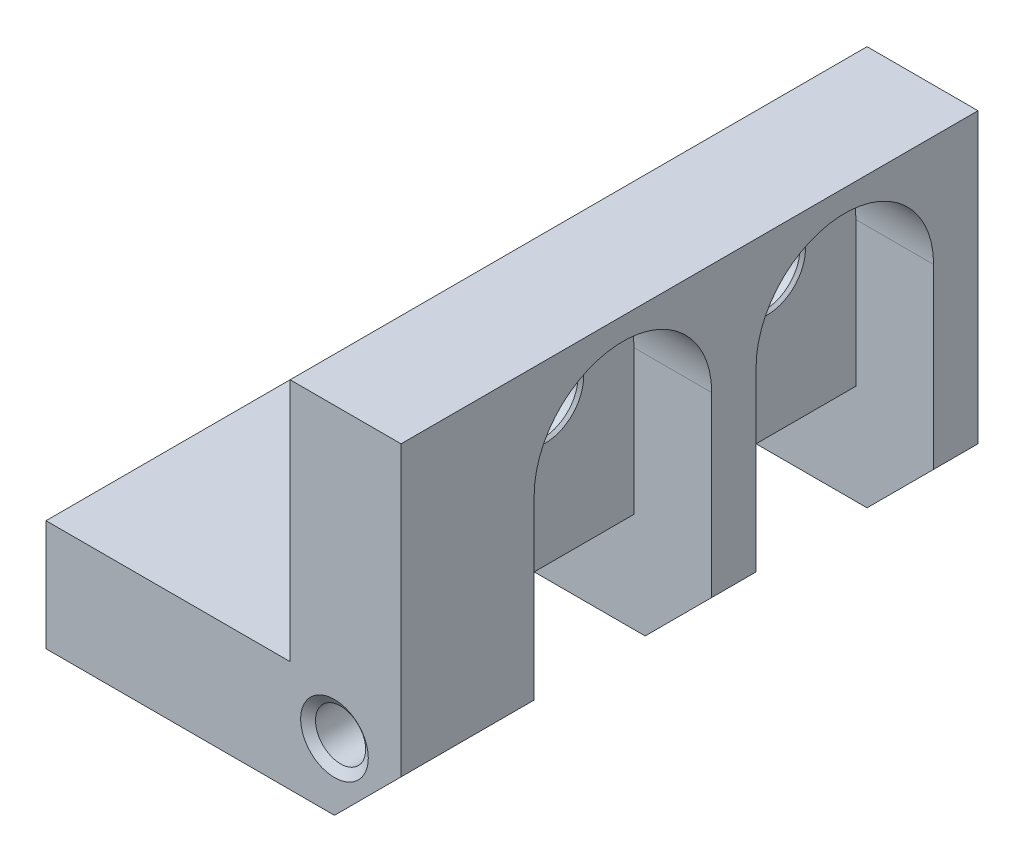
from build123d import *

# Parameters (mm, degrees)
SKETCH_1_W                    = 16
SKETCH_1_H                    = 16
EXTRUDE_1_DEPTH               = 26
CUT_EXTRUDE_1_DEPTH           = 29.354893758
CUT_EXTRUDE_2_DEPTH           = 3.5
CUT_EXTRUDE_3_DEPTH           = 3.5
CHAMFER_1_SIZE                = 1
HOLE_WIZARD_4_401_D           = 2.2606
HOLE_WIZARD_4_401_DEPTH       = 6
HOLE_WIZARD_4_401_CSINK_D     = 3.048
HOLE_WIZARD_4_401_CSINK_ANGLE = 110
CHAMFER_3_SIZE                = 3


with BuildPart() as part:
    # Эскиз1 → Вытянуть1 (new body)
    with BuildSketch(Plane.XY):
        Rectangle(SKETCH_1_W, SKETCH_1_H)
    extrude(amount=EXTRUDE_1_DEPTH)

    # Эскиз2 → Вырез-Вытянуть1 (cut, through all)
    with BuildSketch(Plane(origin=(0, 0, 0), x_dir=(-1, 0, 0), z_dir=(0, 0, -1))):
        Polygon((-3, 56.832975678), (-3, 8), (-3, -3), (8, -3), (56.832975678, -3), (125.893232173, 66.060256495), (66.060256495, 125.893232173), align=None)
    extrude(amount=-CUT_EXTRUDE_1_DEPTH, mode=Mode.SUBTRACT)

    # Эскиз9 → Вырез-Вытянуть2 (cut)
    with BuildSketch(Plane(origin=(8, 0, 0), x_dir=(0, 0, -1), z_dir=(1, 0, 0))):
        with BuildLine():
            Line((-20, 3), (-20, -8))
            Line((-20, -8), (-12, -8))
            Line((-12, -8), (-12, 3))
            ThreePointArc((-12, 3), (-16, 7), (-20, 3))
        make_face()
        with BuildLine():
            Line((-10, 3), (-10, -8))
            Line((-10, -8), (-2, -8))
            Line((-2, -8), (-2, 3))
            ThreePointArc((-2, 3), (-6, 7), (-10, 3))
        make_face()
    extrude(amount=-CUT_EXTRUDE_2_DEPTH, mode=Mode.SUBTRACT)

    # Эскиз10 → Вырез-Вытянуть3 (cut)
    with BuildSketch(Plane.XZ.offset(8)):
        with BuildLine():
            Line((4.5, 20), (-3, 20))
            ThreePointArc((-3, 20), (-7, 16), (-3, 12))
            Line((-3, 12), (4.5, 12))
            Line((4.5, 12), (4.5, 20))
        make_face()
        with BuildLine():
            Line((4.5, 10), (-3, 10))
            ThreePointArc((-3, 10), (-7, 6), (-3, 2))
            Line((-3, 2), (4.5, 2))
            Line((4.5, 2), (4.5, 10))
        make_face()
    extrude(amount=-CUT_EXTRUDE_3_DEPTH, mode=Mode.SUBTRACT)

    # Фаска1
    chamfer_1_edges = [part.edges().sort_by_distance(p)[0] for p in [
        (4.5, -4.5, 16),
        (4.5, -4.5, 6),
    ]]
    chamfer(chamfer_1_edges, length=CHAMFER_1_SIZE)

    # Отверстие обработанное метчиком #4-401
    with Locations(Plane(origin=(-3.054370164, -0.984217205, 26), x_dir=(-1, 0, 0), z_dir=(0, 0, 1))):
        with Locations((-8.054370164, 4.015782795)):
            CounterSinkHole(HOLE_WIZARD_4_401_D / 2, HOLE_WIZARD_4_401_CSINK_D / 2, depth=HOLE_WIZARD_4_401_DEPTH, counter_sink_angle=HOLE_WIZARD_4_401_CSINK_ANGLE)

    # Эскиз11 → Отверстие с зазором M31 (revolve, cut)
    with BuildSketch(Plane(origin=(-3, -4.5, 16), x_dir=(0, 0, -1), z_dir=(1, 0, 0))):
        Polygon((0, 0), (0, 1.5), (1.725, 1.5), (1.6, 1.375), (1.6, 0.125), (1.725, 0), align=None)
    revolve(axis=Axis((-3, -10.85, 16), (0, 1, 0)), mode=Mode.SUBTRACT)

    # Эскиз11 at point 2 (carried to point 2, square into its face) → Отверстие с зазором M31 at 2 (revolve, cut)
    with BuildSketch(Plane(origin=(-3, -4.5, 6), x_dir=(0, 0, -1), z_dir=(1, 0, 0))):
        Polygon((0, 0), (0, 1.5), (1.725, 1.5), (1.6, 1.375), (1.6, 0.125), (1.725, 0), align=None)
    revolve(axis=Axis((-3, -10.85, 6), (0, 1, 0)), mode=Mode.SUBTRACT)

    # Эскиз11 at point 3 (carried to point 3, square into its face) → Отверстие с зазором M31 at 3 (revolve, cut)
    with BuildSketch(Plane(origin=(4.5, 3, 6), x_dir=(0, 0, -1), z_dir=(0, 1, 0))):
        Polygon((0, 0), (0, 1.5), (1.725, 1.5), (1.6, 1.375), (1.6, 0.125), (1.725, 0), align=None)
    revolve(axis=Axis((10.85, 3, 6), (-1, 0, 0)), mode=Mode.SUBTRACT)

    # Эскиз11 at point 4 (carried to point 4, square into its face) → Отверстие с зазором M31 at 4 (revolve, cut)
    with BuildSketch(Plane(origin=(4.5, 3, 16), x_dir=(0, 0, -1), z_dir=(0, 1, 0))):
        Polygon((0, 0), (0, 1.5), (1.725, 1.5), (1.6, 1.375), (1.6, 0.125), (1.725, 0), align=None)
    revolve(axis=Axis((10.85, 3, 16), (-1, 0, 0)), mode=Mode.SUBTRACT)

    # Фаска3
    chamfer_3_edges = [part.edges().sort_by_distance(p)[0] for p in [
        (8, -8, 11),
        (8, -8, 1),
        (8, -8, 23),
    ]]
    chamfer(chamfer_3_edges, length=CHAMFER_3_SIZE)


solid = part.part
